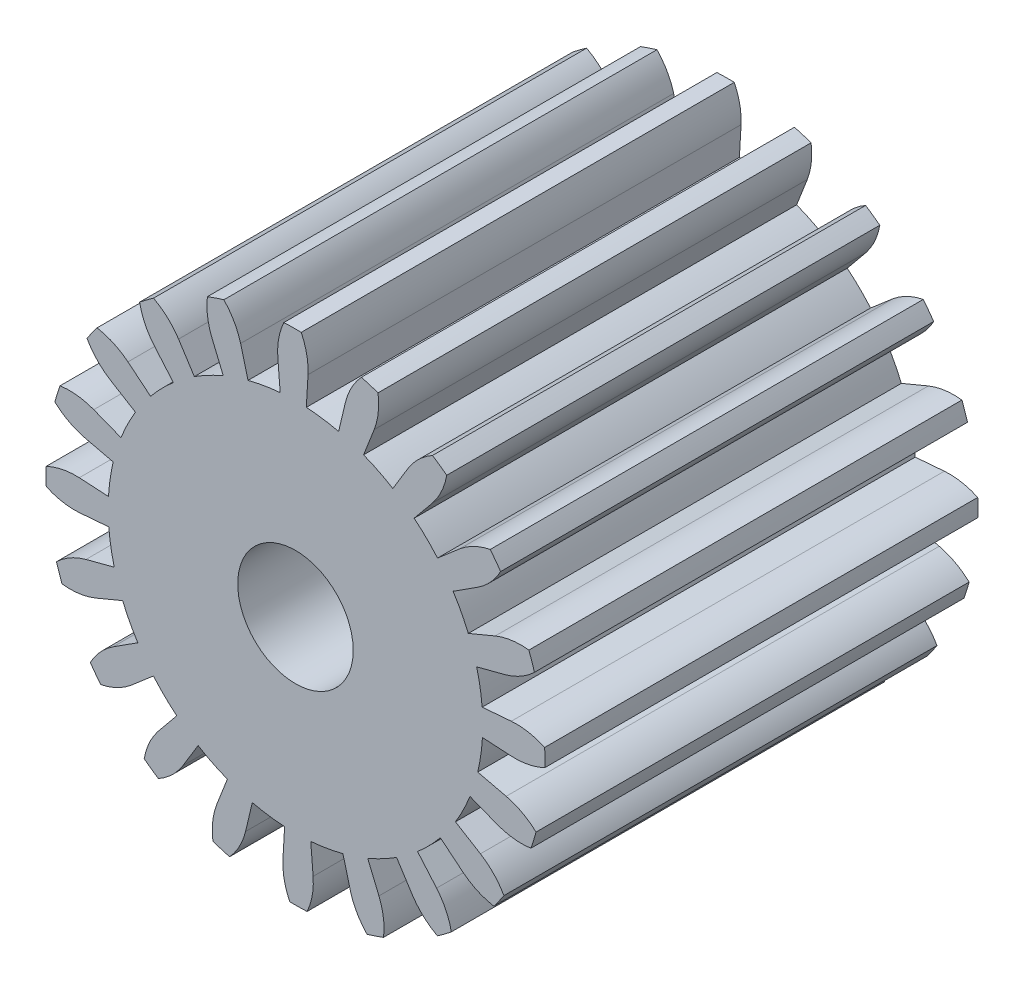
from build123d import *

# Parameters (mm, degrees)
BOSS_EXTRUDE5_DEPTH = 20
CIRPATTERN2_COUNT   = 20
SKETCH4_R           = 2.667
CUT_EXTRUDE1_DEPTH  = 21


with BuildPart() as part:
    # Sketch2 → Boss-Extrude5 (new body)
    with BuildSketch(Plane.XY):
        with BuildLine():
            Line((7.981268161, 3.334945058), (9.226899608, 3.855427813))
            ThreePointArc((9.226899608, 3.855427813), (9.989381492, 4.059662362), (10.778697334, 4.06808118))
            ThreePointArc((10.778697334, 4.06808118), (10.848053492, 3.879347384), (10.914105228, 3.689431902))
            ThreePointArc((10.914105228, 3.689431902), (10.976832422, 3.498392584), (11.036215967, 3.306287621))
            ThreePointArc((11.036215967, 3.306287621), (10.403686481, 2.834062226), (9.6736759, 2.533770824))
            Line((9.6736759, 2.533770824), (8.367729653, 2.191711763))
            ThreePointArc((8.367729653, 2.191711763), (8.455366553, 1.824630498), (8.526908182, 1.454075945))
            Line((8.526908182, 1.454075945), (0, 0))
            Line((0, 0), (7.660237412, 4.01786794))
            ThreePointArc((7.660237412, 4.01786794), (7.828203502, 3.679908957), (7.981268161, 3.334945058))
        make_face()
    boss_extrude5 = extrude(amount=BOSS_EXTRUDE5_DEPTH)

    # CirPattern2: Boss-Extrude5 ×20 about axis
    cirpattern2_axis = Axis((0, 0, 0), (0, 0, 1))
    for i in range(1, CIRPATTERN2_COUNT):
        add(boss_extrude5.rotate(cirpattern2_axis, i * 360 / CIRPATTERN2_COUNT))

    # Sketch4 → Cut-Extrude1 (cut, through all)
    with BuildSketch(Plane.XY.offset(20)):
        Circle(SKETCH4_R)
    extrude(amount=-CUT_EXTRUDE1_DEPTH, mode=Mode.SUBTRACT)


solid = part.part
